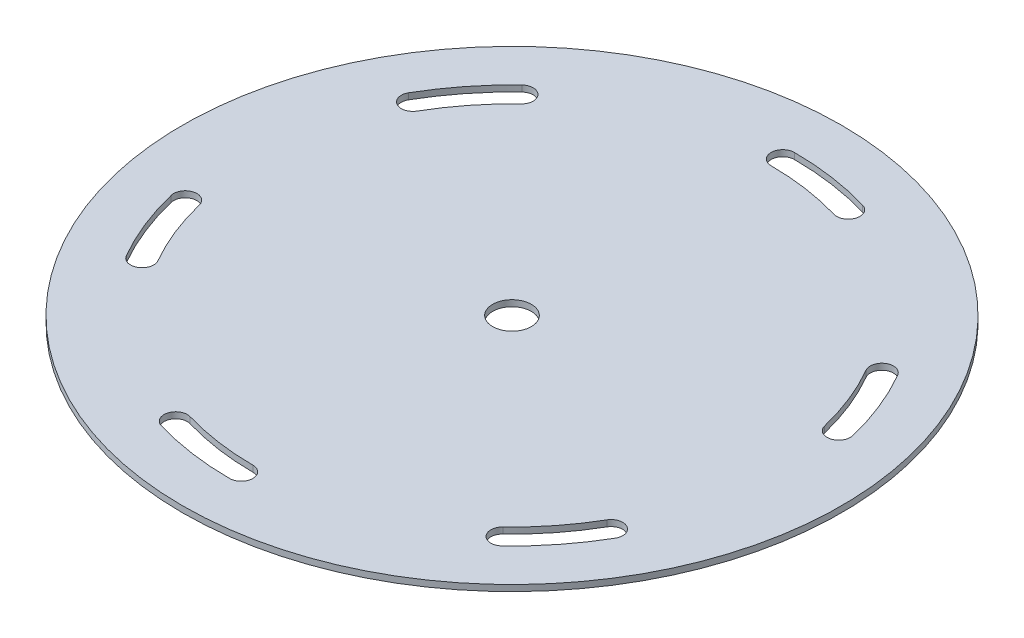
from build123d import *

# Parameters (mm, degrees)
SKETCH1_R           = 85.2
SKETCH1_R_2         = 5
BOSS_EXTRUDE1_DEPTH = 1.5875


with BuildPart() as part:
    # Sketch1 → Boss-Extrude1 (new body)
    with BuildSketch(Plane(origin=(0, 0, 0), x_dir=(1, 0, 0), z_dir=(0, 1, 0))):
        Circle(SKETCH1_R)
        Circle(SKETCH1_R_2, mode=Mode.SUBTRACT)
        with BuildLine():
            ThreePointArc((70.961061147, 17.132653061), (67.785714286, 27.094223347), (63.219854476, 36.5))
            ThreePointArc((63.219854476, 36.5), (59.121778265, 37.598076211), (58.023702054, 33.5))
            ThreePointArc((58.023702054, 33.5), (62.214285714, 24.86730088), (65.128645162, 15.724489796))
            ThreePointArc((65.128645162, 15.724489796), (68.748934787, 13.512363436), (70.961061147, 17.132653061))
        make_face(mode=Mode.SUBTRACT)
        with BuildLine():
            ThreePointArc((20.643217788, 70.020408163), (10.428571429, 72.251262259), (0, 73))
            ThreePointArc((0, 73), (-3, 70), (0, 67))
            ThreePointArc((0, 67), (9.571428571, 66.312802347), (18.946514956, 64.265306122))
            ThreePointArc((18.946514956, 64.265306122), (22.672417393, 66.294505727), (20.643217788, 70.020408163))
        make_face(mode=Mode.SUBTRACT)
        with BuildLine():
            ThreePointArc((50.317843359, -52.887755102), (57.357142857, -45.157038912), (63.219854476, -36.5))
            ThreePointArc((63.219854476, -36.5), (62.121778265, -32.401923789), (58.023702054, -33.5))
            ThreePointArc((58.023702054, -33.5), (52.642857143, -41.445501467), (46.182130206, -48.540816327))
            ThreePointArc((46.182130206, -48.540816327), (46.076517395, -52.782142291), (50.317843359, -52.887755102))
        make_face(mode=Mode.SUBTRACT)
        with BuildLine():
            ThreePointArc((-20.643217788, -70.020408163), (-10.428571429, -72.251262259), (0, -73))
            ThreePointArc((0, -73), (3, -70), (0, -67))
            ThreePointArc((0, -67), (-9.571428571, -66.312802347), (-18.946514956, -64.265306122))
            ThreePointArc((-18.946514956, -64.265306122), (-22.672417393, -66.294505727), (-20.643217788, -70.020408163))
        make_face(mode=Mode.SUBTRACT)
        with BuildLine():
            ThreePointArc((-70.961061147, -17.132653061), (-67.785714286, -27.094223347), (-63.219854476, -36.5))
            ThreePointArc((-63.219854476, -36.5), (-59.121778265, -37.598076211), (-58.023702054, -33.5))
            ThreePointArc((-58.023702054, -33.5), (-62.214285714, -24.86730088), (-65.128645162, -15.724489796))
            ThreePointArc((-65.128645162, -15.724489796), (-68.748934787, -13.512363436), (-70.961061147, -17.132653061))
        make_face(mode=Mode.SUBTRACT)
        with BuildLine():
            ThreePointArc((-50.317843359, 52.887755102), (-57.357142857, 45.157038912), (-63.219854476, 36.5))
            ThreePointArc((-63.219854476, 36.5), (-62.121778265, 32.401923789), (-58.023702054, 33.5))
            ThreePointArc((-58.023702054, 33.5), (-52.642857143, 41.445501467), (-46.182130206, 48.540816327))
            ThreePointArc((-46.182130206, 48.540816327), (-46.076517395, 52.782142291), (-50.317843359, 52.887755102))
        make_face(mode=Mode.SUBTRACT)
    extrude(amount=BOSS_EXTRUDE1_DEPTH)


solid = part.part
